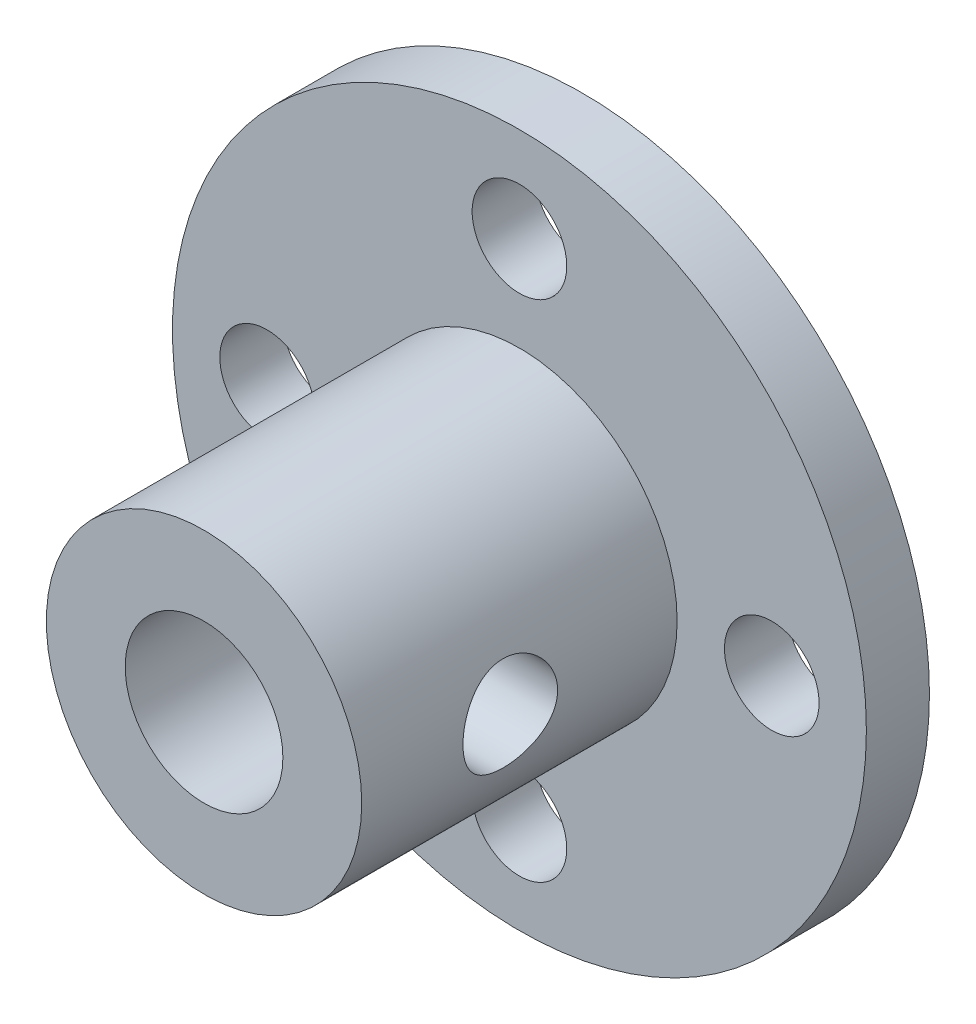
from build123d import *

# Parameters (mm, degrees)
SKETCH_1_R               = 11
EXTRUDE_1_DEPTH          = 2
SKETCH_2_R               = 5
SKETCH_2_R_2             = 2.5
EXTRUDE_2_DEPTH          = 10
SKETCH_3_R               = 1.5
CUT_EXTRUDE_1_DEPTH      = 3
SKETCH_4_R               = 1.5
CUT_EXTRUDE_2_DEPTH      = 12
CUT_EXTRUDE_2_DEPTH_BACK = 12


with BuildPart() as part:
    # 草图1 → 凸台-拉伸1 (new body)
    with BuildSketch(Plane.XY):
        Circle(SKETCH_1_R)
    extrude(amount=EXTRUDE_1_DEPTH)

    # 草图2 → 凸台-拉伸2 (add)
    with BuildSketch(Plane.XY.offset(2)):
        Circle(SKETCH_2_R)
        Circle(SKETCH_2_R_2, mode=Mode.SUBTRACT)
    extrude(amount=EXTRUDE_2_DEPTH)

    # 草图3 → 切除-拉伸1 (cut, through all)
    with BuildSketch(Plane.XY.offset(2)):
        with Locations((0, 8)):
            Circle(SKETCH_3_R)
        with Locations((8, 0)):
            Circle(SKETCH_3_R)
        with Locations((0, -8)):
            Circle(SKETCH_3_R)
        with Locations((-8, 0)):
            Circle(SKETCH_3_R)
    extrude(amount=-CUT_EXTRUDE_1_DEPTH, mode=Mode.SUBTRACT)

    # 草图4 → 切除-拉伸2 (cut, two sides)
    with BuildSketch(Plane(origin=(0, 0, 0), x_dir=(0, 0, -1), z_dir=(1, 0, 0))) as cut_extrude_2_sk:
        with Locations((-7.289607981, 0)):
            Circle(SKETCH_4_R)
    extrude(amount=CUT_EXTRUDE_2_DEPTH, mode=Mode.SUBTRACT)
    extrude(cut_extrude_2_sk.sketch, amount=-CUT_EXTRUDE_2_DEPTH_BACK, mode=Mode.SUBTRACT)


solid = part.part
